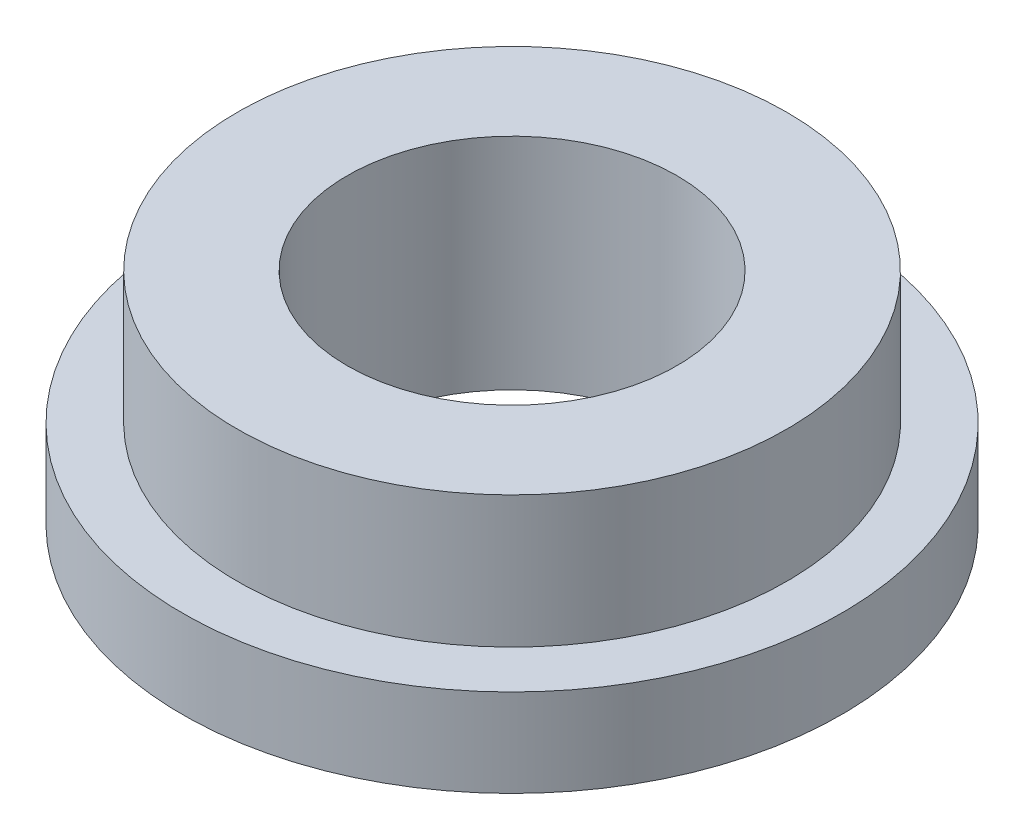
from build123d import *


with BuildPart() as part:
    # Esquisse1 → Révolution1 (revolve)
    with BuildSketch(Plane(origin=(0, 0, 0), x_dir=(0, 0, -1), z_dir=(1, 0, 0))):
        Polygon((3, 0), (3, 4), (5, 4), (5, 1.6), (6, 1.6), (6, 0), align=None)
    revolve(axis=Axis((0, -11.7, 0), (0, 1, 0)))


solid = part.part
